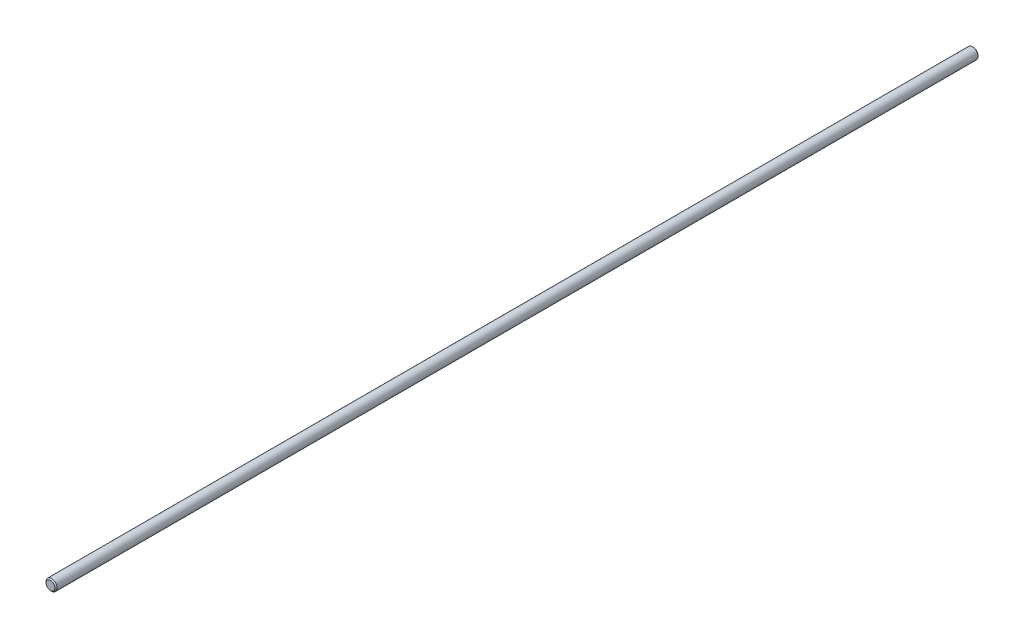
from build123d import *

# Parameters (mm, degrees)
ESQUISSE1_R        = 3
BOSS_EXTRU_1_DEPTH = 500
CHANFREIN1_SIZE    = 0.6


with BuildPart() as part:
    # Esquisse1 → Boss.-Extru.1 (new body)
    with BuildSketch(Plane.XY):
        Circle(ESQUISSE1_R)
    extrude(amount=BOSS_EXTRU_1_DEPTH)

    # Chanfrein1
    chanfrein1_edges = [part.edges().sort_by_distance(p)[0] for p in [
        (-3, 0, 0),
        (-3, 0, 500),
    ]]
    chamfer(chanfrein1_edges, length=CHANFREIN1_SIZE)


solid = part.part
